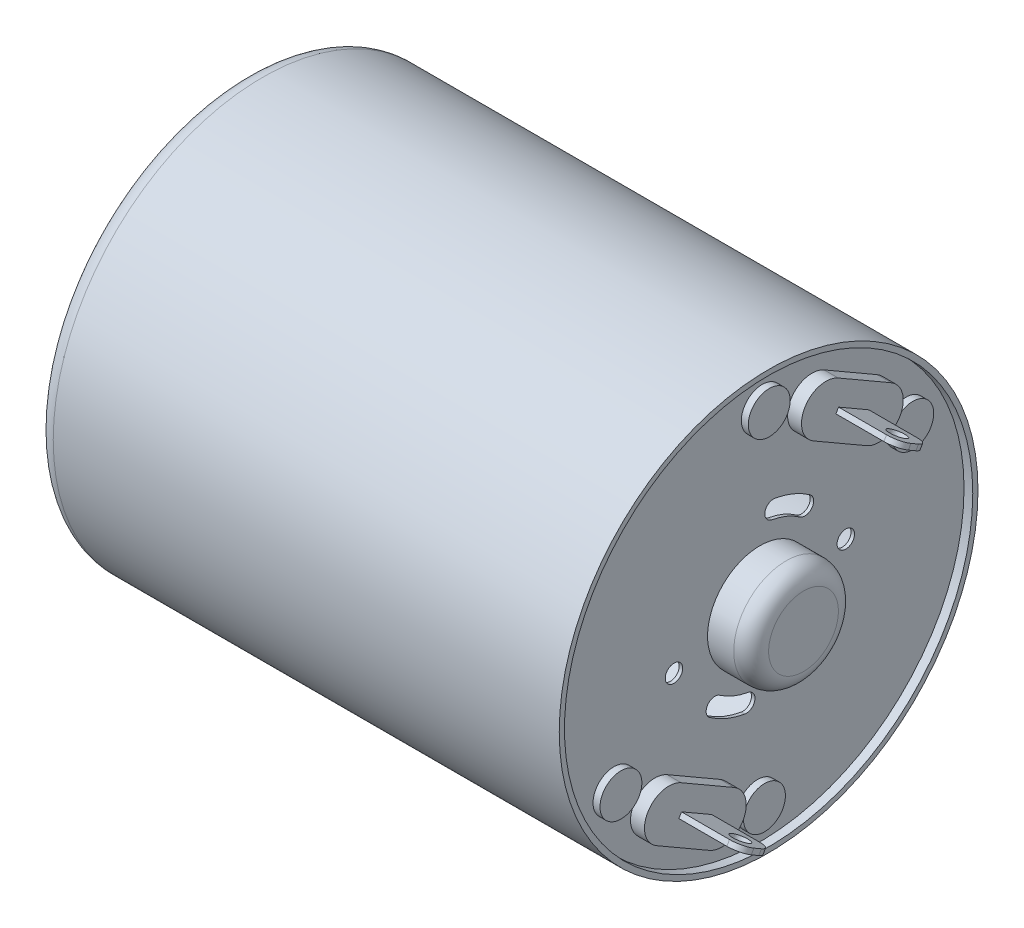
from build123d import *

# Parameters (mm, degrees)
SKETCH1_R                = 12
SKETCH1_R_2              = 11.7
BOSS_EXTRUDE1_DEPTH      = 30
SKETCH2_R                = 11.7
BOSS_EXTRUDE2_DEPTH      = 0.2
SKETCH3_R                = 3
BOSS_EXTRUDE3_DEPTH      = 2.5
FILLET1_R                = 1
CUT_EXTRUDE1_DEPTH       = 30.5
CIRPATTERN1_COUNT        = 2
SKETCH5_R                = 0.5
CUT_EXTRUDE2_DEPTH       = 30.5
CIRPATTERN2_COUNT        = 2
SKETCH7_R                = 11.7
BOSS_EXTRUDE4_DEPTH      = 0.3
CUT_EXTRUDE3_REACH       = 34
SKETCH9_R                = 3
BOSS_EXTRUDE5_DEPTH      = 0.8
SKETCH10_R               = 1.2
BOSS_EXTRUDE6_DEPTH      = 0.4
BOSS_EXTRUDE7_DEPTH      = 3.5
SKETCH12_R               = 0.5
CUT_EXTRUDE4_DEPTH       = 8.542304845
FILLET3_R                = 0.75
CIRPATTERN3_COUNT        = 2
FILLET3_OF_CIRPATTERN3_R = 0.75
SKETCH13_R               = 3
BOSS_EXTRUDE8_DEPTH      = 0.3
SKETCH14_R               = 1
CUT_EXTRUDE5_DEPTH       = 0.3
FILLET2_R                = 1
CIRPATTERN4_COUNT        = 2


with BuildPart() as part:
    # Sketch1 → Boss-Extrude1 (new body)
    with BuildSketch(Plane(origin=(0, 0, 0), x_dir=(0, 0, -1), z_dir=(1, 0, 0))):
        Circle(SKETCH1_R)
        Circle(SKETCH1_R_2, mode=Mode.SUBTRACT)
    extrude(amount=-BOSS_EXTRUDE1_DEPTH)

    # Sketch2 → Boss-Extrude2 (add)
    with BuildSketch(Plane(origin=(-0.5, 0, 0), x_dir=(0, 0, -1), z_dir=(1, 0, 0))):
        Circle(SKETCH2_R)
    extrude(amount=-BOSS_EXTRUDE2_DEPTH)

    # Sketch3 → Boss-Extrude3 (add)
    with BuildSketch(Plane(origin=(-0.5, 0, 0), x_dir=(0, 0, -1), z_dir=(1, 0, 0))):
        Circle(SKETCH3_R)
    extrude(amount=BOSS_EXTRUDE3_DEPTH)

    # Fillet1
    fillet1_edges = [part.edges().sort_by_distance(p)[0] for p in [
        (2, 0, 3),
    ]]
    fillet(fillet1_edges, radius=FILLET1_R)

    # Sketch4 → Cut-Extrude1 (cut, through all)
    with BuildSketch(Plane(origin=(-0.5, 0, 0), x_dir=(0, 0, -1), z_dir=(1, 0, 0))):
        with BuildLine():
            ThreePointArc((2.867882182, 4.095760221), (1.913417162, 4.619397663), (0.868240888, 4.924038765))
            ThreePointArc((0.868240888, 4.924038765), (0.289012923, 4.518458977), (0.694592711, 3.939231012))
            ThreePointArc((0.694592711, 3.939231012), (1.530733729, 3.69551813), (2.294305745, 3.276608177))
            ThreePointArc((2.294305745, 3.276608177), (2.990669986, 3.399395981), (2.867882182, 4.095760221))
        make_face()
    cut_extrude1 = extrude(amount=-CUT_EXTRUDE1_DEPTH, mode=Mode.SUBTRACT)

    # CirPattern1: Cut-Extrude1 ×2 about axis
    cirpattern1_axis = Axis((0, 0, 0), (1, 0, 0))
    for i in range(1, CIRPATTERN1_COUNT):
        add(cut_extrude1.rotate(cirpattern1_axis, i * 360 / CIRPATTERN1_COUNT), mode=Mode.SUBTRACT)

    # Sketch5 → Cut-Extrude2 (cut, through all)
    with BuildSketch(Plane(origin=(-0.5, 0, 0), x_dir=(0, 0, -1), z_dir=(1, 0, 0))):
        with Locations((4.924038765, 0.868240888)):
            Circle(SKETCH5_R)
    cut_extrude2 = extrude(amount=-CUT_EXTRUDE2_DEPTH, mode=Mode.SUBTRACT)

    # CirPattern2: Cut-Extrude2 ×2 about axis
    cirpattern2_axis = Axis((0, 0, 0), (1, 0, 0))
    for i in range(1, CIRPATTERN2_COUNT):
        add(cut_extrude2.rotate(cirpattern2_axis, i * 360 / CIRPATTERN2_COUNT), mode=Mode.SUBTRACT)

    # Sketch7 → Boss-Extrude4 (add)
    with BuildSketch(Plane.ZY.offset(30)):
        Circle(SKETCH7_R)
    extrude(amount=-BOSS_EXTRUDE4_DEPTH)

    # Sketch9 → Cut-Extrude3 (cut, up to next)
    with BuildSketch(Plane.ZY.offset(30), mode=Mode.PRIVATE) as cut_extrude3_sk1:
        Circle(SKETCH9_R)
    cut_extrude3_tool1 = extrude(cut_extrude3_sk1.sketch, amount=-CUT_EXTRUDE3_REACH, mode=Mode.PRIVATE) & part.part
    add(cut_extrude3_tool1.solids().sort_by_distance((-30, 0, 0))[0], mode=Mode.SUBTRACT)

    # Sketch6 → Boss-Extrude5 (add)
    with BuildSketch(Plane(origin=(-0.5, 0, 0), x_dir=(0, 0, -1), z_dir=(1, 0, 0))):
        with BuildLine():
            Line((3.684455543, 9.881664199), (6.715544457, 8.131664199))
            ThreePointArc((6.715544457, 8.131664199), (7.227980022, 6.219228634), (5.315544457, 5.706793069))
            Line((5.315544457, 5.706793069), (2.284455543, 7.456793069))
            ThreePointArc((2.284455543, 7.456793069), (1.772019978, 9.369228634), (3.684455543, 9.881664199))
        make_face()
    boss_extrude5 = extrude(amount=BOSS_EXTRUDE5_DEPTH)

    # Sketch10 → Boss-Extrude6 (add)
    with BuildSketch(Plane(origin=(-0.5, 0, 0), x_dir=(0, 0, -1), z_dir=(1, 0, 0))):
        with Locations((0.136379332, 9.736215932)):
            Circle(SKETCH10_R)
        with Locations((8.363620668, 4.986215932)):
            Circle(SKETCH10_R)
    boss_extrude6 = extrude(amount=BOSS_EXTRUDE6_DEPTH)

    # Sketch11 → Boss-Extrude7 (add)
    with BuildSketch(Plane(origin=(0.3, 0, 0), x_dir=(0, 0, -1), z_dir=(1, 0, 0))):
        Polygon((3.708974596, 8.424132445), (5.441025404, 7.424132445), (5.291025404, 7.164324823), (3.558974596, 8.164324823), align=None)
    boss_extrude7 = extrude(amount=BOSS_EXTRUDE7_DEPTH)

    # Sketch12 → Cut-Extrude4 (cut, through all)
    with BuildSketch(Plane(origin=(0, 7.664324823, -4.425), x_dir=(-1, 0, 0), z_dir=(0, -0.866025404, 0.5))):
        with Locations((-2.8, 0)):
            Circle(SKETCH12_R)
    cut_extrude4 = extrude(amount=-CUT_EXTRUDE4_DEPTH, mode=Mode.SUBTRACT)

    # Fillet3
    fillet3_edges = [part.edges().sort_by_distance(p)[0] for p in [
        (3.8, 7.294228634, -5.366025404),
        (3.8, 8.294228634, -3.633974596),
    ]]
    fillet(fillet3_edges, radius=FILLET3_R)

    # CirPattern3: Boss-Extrude5, Boss-Extrude7, Cut-Extrude4 ×2 about axis
    cirpattern3_axis = Axis((0, 0, 0), (1, 0, 0))
    for i in range(1, CIRPATTERN3_COUNT):
        add(boss_extrude5.rotate(cirpattern3_axis, i * 360 / CIRPATTERN3_COUNT))
        add(boss_extrude7.rotate(cirpattern3_axis, i * 360 / CIRPATTERN3_COUNT))
        add(cut_extrude4.rotate(cirpattern3_axis, i * 360 / CIRPATTERN3_COUNT), mode=Mode.SUBTRACT)

    # Fillet3 of CirPattern3
    fillet3_of_cirpattern3_edges = [part.edges().sort_by_distance(p)[0] for p in [
        (3.8, -7.294228634, 5.366025404),
        (3.8, -8.294228634, 3.633974596),
    ]]
    fillet(fillet3_of_cirpattern3_edges, radius=FILLET3_OF_CIRPATTERN3_R)

    # Fillet2
    fillet2_edges = [part.edges().sort_by_distance(p)[0] for p in [
        (-30, 0, 12),
    ]]
    fillet(fillet2_edges, radius=FILLET2_R)

    # CirPattern4: Boss-Extrude6 ×2 about axis
    cirpattern4_axis = Axis((0, 0, 0), (1, 0, 0))
    for i in range(1, CIRPATTERN4_COUNT):
        add(boss_extrude6.rotate(cirpattern4_axis, i * 360 / CIRPATTERN4_COUNT))


with BuildPart() as body_2:
    # Sketch13 → Boss-Extrude8 (new body)
    with BuildSketch(Plane.ZY.offset(30)):
        Circle(SKETCH13_R)
    extrude(amount=-BOSS_EXTRUDE8_DEPTH)

    # Sketch14 → Cut-Extrude5 (cut)
    with BuildSketch(Plane.ZY.offset(30)):
        Circle(SKETCH14_R)
    extrude(amount=-CUT_EXTRUDE5_DEPTH, mode=Mode.SUBTRACT)


solid = Compound([part.part, body_2.part])
